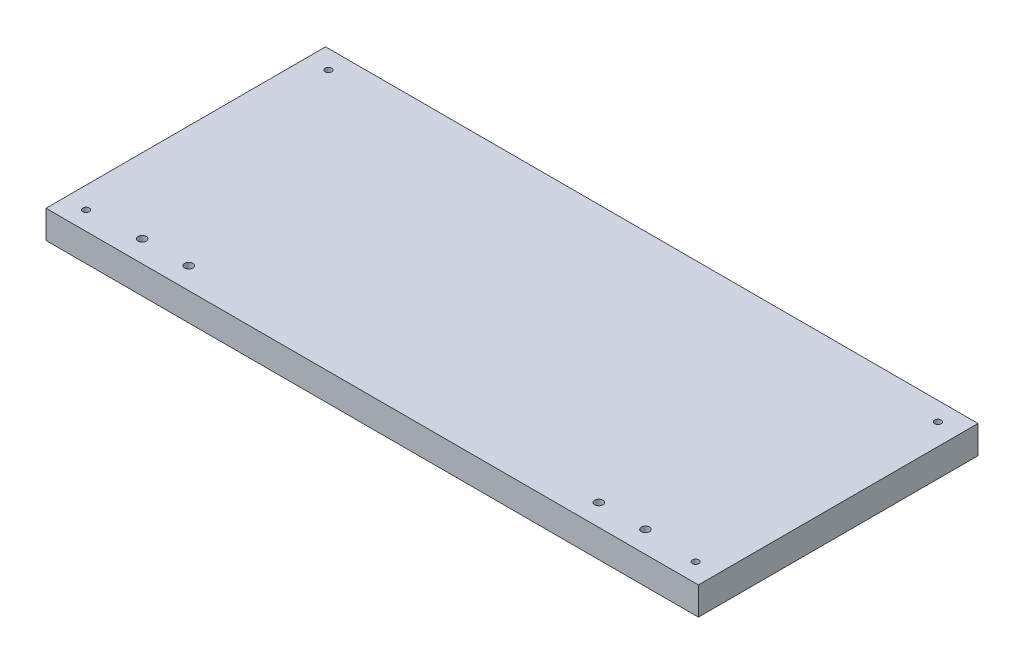
from build123d import *

# Parameters (mm, degrees)
SKETCH1_W           = 350
SKETCH1_H           = 150
SKETCH1_R           = 1.75
BOSS_EXTRUDE1_DEPTH = 15
SKETCH2_R           = 2.2
CUT_EXTRUDE1_DEPTH  = 16


with BuildPart() as part:
    # Sketch1 → Boss-Extrude1 (new body)
    with BuildSketch(Plane(origin=(0, 0, 0), x_dir=(1, 0, 0), z_dir=(0, 1, 0))):
        Rectangle(SKETCH1_W, SKETCH1_H)
        with Locations((163.5, 65)):
            Circle(SKETCH1_R, mode=Mode.SUBTRACT)
        with Locations((163.5, -65)):
            Circle(SKETCH1_R, mode=Mode.SUBTRACT)
        with Locations((-163.5, -65)):
            Circle(SKETCH1_R, mode=Mode.SUBTRACT)
        with Locations((-163.5, 65)):
            Circle(SKETCH1_R, mode=Mode.SUBTRACT)
    extrude(amount=BOSS_EXTRUDE1_DEPTH)

    # Sketch2 → Cut-Extrude1 (cut, through all)
    with BuildSketch(Plane(origin=(0, 15, 0), x_dir=(1, 0, 0), z_dir=(0, 1, 0))):
        with Locations((-135, -63.4)):
            Circle(SKETCH2_R)
        with Locations((-110, -63.4)):
            Circle(SKETCH2_R)
        with Locations((135, -63.4)):
            Circle(SKETCH2_R)
        with Locations((110, -63.4)):
            Circle(SKETCH2_R)
    extrude(amount=-CUT_EXTRUDE1_DEPTH, mode=Mode.SUBTRACT)


solid = part.part
